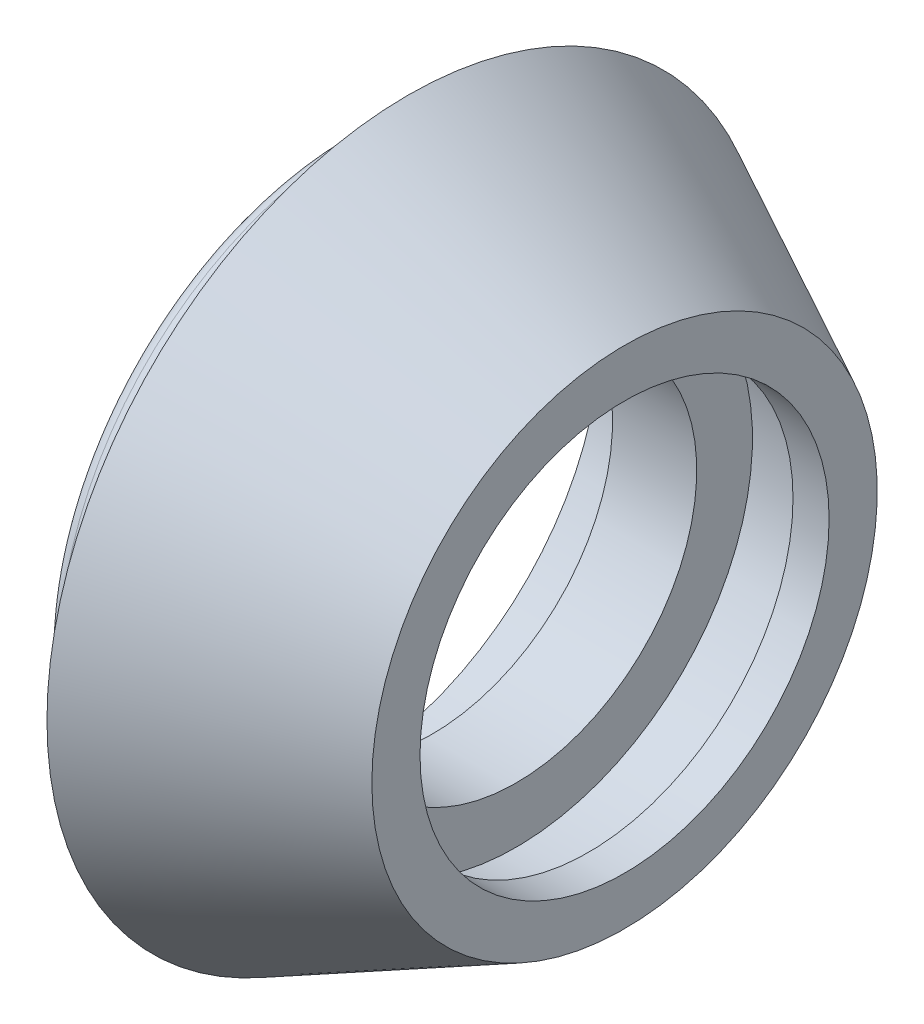
from build123d import *

# Parameters (mm, degrees)
CONG_1_R = 0.5


with BuildPart() as part:
    # Esquisse1 → Révolution1 (revolve)
    with BuildSketch(Plane.XY, mode=Mode.PRIVATE) as r_volution1_sk:
        Polygon((-8, 7.5), (-4.5, 7.5), (-4.5, 9.815), (-1.5, 9.815), (-1.5, 8.5), (0, 8.5), (0, 10.5), (-9, 15), (-9, 12), (-10.5, 12), (-10.5, 12.5), (-11.5, 12.5), (-11.5, 10.5), (-8, 10.5), align=None)
    revolve(r_volution1_sk.sketch.rotate(Axis((-27.606261023, 0, 0), (1, 0, 0)), 90), axis=Axis((-27.606261023, 0, 0), (1, 0, 0)))  # turned: the seam where the file's is

    # Congé1
    cong_1_edges = [part.edges().sort_by_distance(p)[0] for p in [
        (-11.5, 0, -12.5),
    ]]
    fillet(cong_1_edges, radius=CONG_1_R)


solid = part.part
